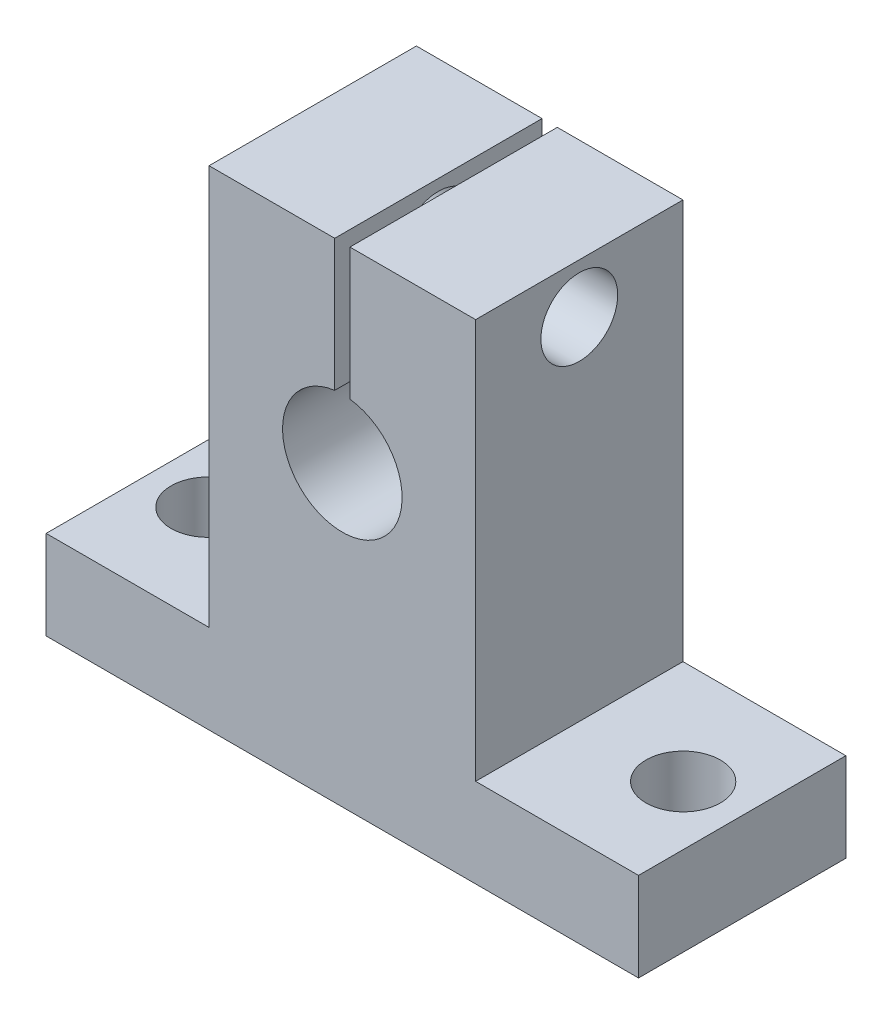
from build123d import *

# Parameters (mm, degrees)
SALIENTE_EXTRUIR1_DEPTH = 14
CROQUIS2_R              = 4.035649311
CORTAR_EXTRUIR1_DEPTH   = 14
CROQUIS5_R              = 2.497749653
CORTAR_EXTRUIR2_DEPTH   = 14
CROQUIS7_R              = 2.514867633
CORTAR_EXTRUIR3_DEPTH   = 14
CROQUIS8_W              = 1.02892534
CROQUIS8_H              = 10.439450899
CORTAR_EXTRUIR4_DEPTH   = 14
CROQUIS9_R              = 2.593975345
CORTAR_EXTRUIR5_DEPTH   = 30


with BuildPart() as part:
    # Croquis1 → Saliente-Extruir1 (new body)
    with BuildSketch(Plane.XY):
        Polygon((-2.000386176, 17.69916911), (15.999613824, 17.69916911), (15.999613824, -9.30083089), (26.999613824, -9.30083089), (26.999613824, -15.30083089), (15.999613824, -15.30083089), (-2.000386176, -15.30083089), (-13.000386176, -15.30083089), (-13.000386176, -9.30083089), (-2.000386176, -9.30083089), align=None)
    extrude(amount=SALIENTE_EXTRUIR1_DEPTH)

    # Croquis2 → Cortar-Extruir1 (cut)
    with BuildSketch(Plane.XY.offset(14)):
        with Locations((6.999613824, 4.803097651)):
            Circle(CROQUIS2_R)
    extrude(amount=-CORTAR_EXTRUIR1_DEPTH, mode=Mode.SUBTRACT)

    # Croquis5 → Cortar-Extruir2 (cut)
    with BuildSketch(Plane(origin=(0, -9.30083089, 0), x_dir=(1, 0, 0), z_dir=(0, 1, 0))):
        with Locations((-9.06576441, -7)):
            Circle(CROQUIS5_R)
    extrude(amount=-CORTAR_EXTRUIR2_DEPTH, mode=Mode.SUBTRACT)

    # Croquis7 → Cortar-Extruir3 (cut)
    with BuildSketch(Plane(origin=(0, -9.30083089, 0), x_dir=(1, 0, 0), z_dir=(0, 1, 0))):
        with Locations((23.014515722, -7)):
            Circle(CROQUIS7_R)
    extrude(amount=-CORTAR_EXTRUIR3_DEPTH, mode=Mode.SUBTRACT)

    # Croquis8 → Cortar-Extruir4 (cut)
    with BuildSketch(Plane.XY.offset(14)):
        with Locations((6.999613824, 13.435682)):
            Rectangle(CROQUIS8_W, CROQUIS8_H)
    extrude(amount=-CORTAR_EXTRUIR4_DEPTH, mode=Mode.SUBTRACT)

    # Croquis9 → Cortar-Extruir5 (cut, through all)
    with BuildSketch(Plane.ZY.offset(2.000386176)):
        with Locations((7, 14.351263228)):
            Circle(CROQUIS9_R)
    extrude(amount=-CORTAR_EXTRUIR5_DEPTH, mode=Mode.SUBTRACT)


solid = part.part
